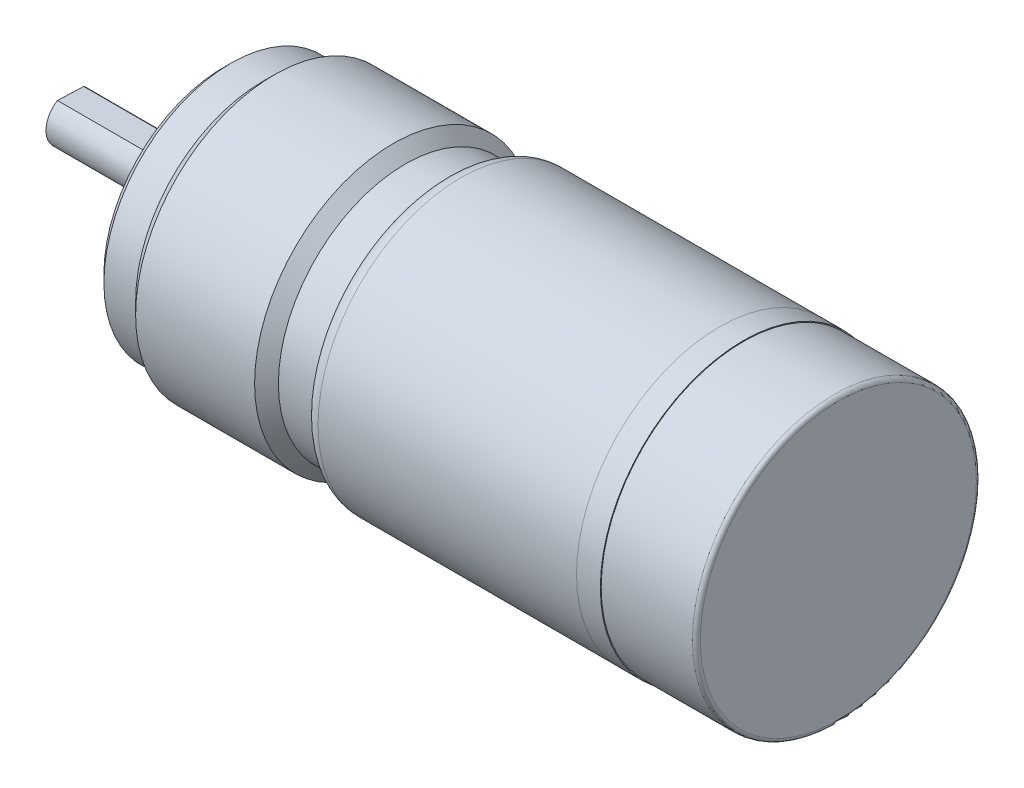
from build123d import *

# Parameters (mm, degrees)
SKETCH_1_W               = 16.3
SKETCH_1_H               = 3
SKETCH_1_W_2             = 5
SKETCH_1_H_2             = 16
SKETCH_4_R               = 18
EXTRUDE_1_DEPTH          = 14
SKETCH_5_R               = 18
CUT_EXTRUDE_2_DEPTH      = 3.5
CUT_EXTRUDE_4_DEPTH      = 12
SKETCH_8_W               = 12
SKETCH_8_H               = 0.1
FILLET_3_R               = 0.5
SKETCH_10_W              = 3
SKETCH_10_H              = 0.01
CUT_EXTRUDE_6_DEPTH      = 3
SKETCH_13_R              = 1.5
CUT_EXTRUDE_8_DEPTH      = 7
PATTERN_CIRCULAR_2_COUNT = 4


with BuildPart() as part:
    # Эскиз1 → Повернуть1 (revolve)
    with BuildSketch(Plane(origin=(0, 0, 0), x_dir=(1, 0, 0), z_dir=(0, 1, 0))):
        with Locations((8.15, 1.5)):
            Rectangle(SKETCH_1_W, SKETCH_1_H)
        Polygon((16.3, 0), (19.3, 0), (19.3, 10), (16.3, 10), (16.3, 3), align=None)
        Polygon((24.3, 0), (24.3, 16), (20.3, 16), (19.3, 15), (19.3, 10), (19.3, 0), align=None)
        Polygon((40.8, 17.5), (42.3, 16), (42.3, 0), (24.3, 0), (24.3, 16), (25.8, 17.5), align=None)
        with Locations((44.8, 8)):
            Rectangle(SKETCH_1_W_2, SKETCH_1_H_2)
        with BuildLine():
            ThreePointArc((47.3, 16), (47.885786438, 17.414213562), (49.3, 18))
            Line((49.3, 18), (86.4, 18))
            Line((86.4, 18), (86.4, 0))
            Line((86.4, 0), (47.3, 0))
            Line((47.3, 0), (47.3, 16))
        make_face()
    revolve(axis=Axis((0, 0, 0), (1, 0, 0)))

    # Эскиз4 → Бобышка-Вытянуть1 (add)
    with BuildSketch(Plane(origin=(86.4, 0, 0), x_dir=(0, 0, -1), z_dir=(1, 0, 0))):
        Circle(SKETCH_4_R)
    extrude(amount=EXTRUDE_1_DEPTH)

    # Эскиз5 → Вырез-Вытянуть2 (cut)
    with BuildSketch(Plane(origin=(100.4, 0, 0), x_dir=(0, 0, -1), z_dir=(1, 0, 0))):
        Circle(SKETCH_5_R)
    extrude(amount=-CUT_EXTRUDE_2_DEPTH, mode=Mode.SUBTRACT)

    # Эскиз6 → Вырез-Вытянуть4 (cut)
    with BuildSketch(Plane.ZY):
        with BuildLine():
            Line((-1.75306936, 2.434491286), (1.561110291, 2.561822527))
            ThreePointArc((1.561110291, 2.561822527), (-0.115175441, 2.997788288), (-1.75306936, 2.434491286))
        make_face()
    extrude(amount=-CUT_EXTRUDE_4_DEPTH, mode=Mode.SUBTRACT)

    # Вырез-По траектории3: sweep along a path in Эскиз9
    with BuildLine(Plane(origin=(96.9, 0, 0), x_dir=(0, 0, -1), z_dir=(1, 0, 0))) as sweep_3_path:
        CenterArc((0, 0), 17.9, 0, 360)
    # Эскиз8 → Вырез-По траектории3 (sweep, cut)
    with BuildSketch(Plane(origin=(0, 0, 0), x_dir=(1, 0, 0), z_dir=(0, 1, 0))):
        with Locations((90.9, -17.95)):
            Rectangle(SKETCH_8_W, SKETCH_8_H)
    sweep(path=sweep_3_path.line, mode=Mode.SUBTRACT)

    # Скругление3
    fillet_3_edges = [part.edges().sort_by_distance(p)[0] for p in [
        (96.9, 0, 17.9),
    ]]
    fillet(fillet_3_edges, radius=FILLET_3_R)

    # Эскиз10 → Повернуть2 (revolve)
    with BuildSketch(Plane(origin=(0, 0, 0), x_dir=(1, 0, 0), z_dir=(0, 1, 0))):
        with Locations((83.4, 18.005)):
            Rectangle(SKETCH_10_W, SKETCH_10_H)
    revolve(axis=Axis((0, 0, 0), (1, 0, 0)))

    # Эскиз11 → Вырез-Вытянуть6 (cut)
    with BuildSketch(Plane.ZY.offset(-16.3)):
        with BuildLine():
            ThreePointArc((4.358898944, 9), (0, 10), (-4.358898944, 9))
            Line((-4.358898944, 9), (4.358898944, 9))
        make_face()
        with BuildLine():
            Line((4.358898944, -9), (-4.358898944, -9))
            ThreePointArc((-4.358898944, -9), (0, -10), (4.358898944, -9))
        make_face()
    extrude(amount=-CUT_EXTRUDE_6_DEPTH, mode=Mode.SUBTRACT)

    # Эскиз13 → Вырез-Вытянуть8 (cut)
    with BuildSketch(Plane.ZY.offset(-19.3)):
        with Locations((-9.192388155, 9.192388155)):
            Circle(SKETCH_13_R)
    cut_extrude_8 = extrude(amount=-CUT_EXTRUDE_8_DEPTH, mode=Mode.SUBTRACT)

    # Круговой массив2: Вырез-Вытянуть8 ×4 about axis
    pattern_circular_2_axis = Axis((0, 0, 0), (1, 0, 0))
    for i in range(1, PATTERN_CIRCULAR_2_COUNT):
        add(cut_extrude_8.rotate(pattern_circular_2_axis, i * 360 / PATTERN_CIRCULAR_2_COUNT), mode=Mode.SUBTRACT)


solid = part.part
